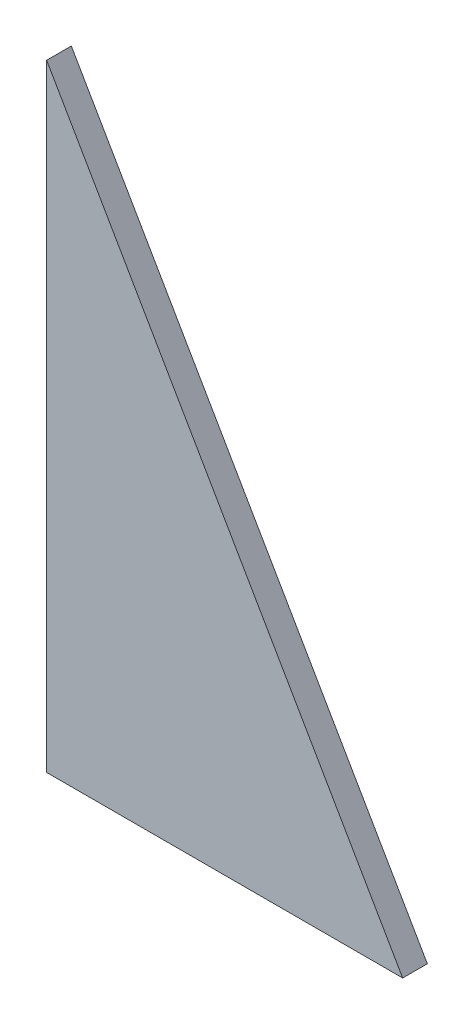
from build123d import *

# Parameters (mm, degrees)
EXTRUDE1_DEPTH = 2.54
EXTRUDE3_DEPTH = 2.032
EXTRUDE2_DEPTH = 0.9144
FILLET1_R      = 1.5875


with BuildPart() as part:
    # Sketch1 → Extrude1 (new body)
    with BuildSketch(Plane.XY):
        Polygon((0, 63.5), (36.6522, 0), (0, 0), align=None)
    extrude(amount=EXTRUDE1_DEPTH)

    # Sketch4 → Extrude3 (cut)
    with BuildSketch(Plane(origin=(0, 0, 0), x_dir=(-1, 0, 0), z_dir=(0, 0, -1))):
        Polygon((0, 31.75), (0, 35.306), (-10.668, 35.306), (-10.668, 28.194), (0, 28.194), align=None)
    extrude(amount=-EXTRUDE3_DEPTH, mode=Mode.SUBTRACT)

    # Sketch3 → Extrude2 (cut)
    with BuildSketch(Plane(origin=(0, 0, 0), x_dir=(-1, 0, 0), z_dir=(0, 0, -1))):
        Polygon((-2.54, 31.75), (-2.54, 20.955), (-19.315938, 20.955), (-6.85419, 42.545), (-2.54, 42.545), align=None)
    extrude(amount=-EXTRUDE2_DEPTH, mode=Mode.SUBTRACT)

    # Fillet1
    fillet1_edges = [part.edges().sort_by_distance(p)[0] for p in [
        (10.668, 28.194, 1.4732),
        (10.668, 35.306, 1.4732),
        (2.54, 42.545, 0.4572),
        (2.54, 20.955, 0.4572),
        (19.315938, 20.955, 0.4572),
        (6.85419, 42.545, 0.4572),
    ]]
    fillet(fillet1_edges, radius=FILLET1_R)


solid = part.part
